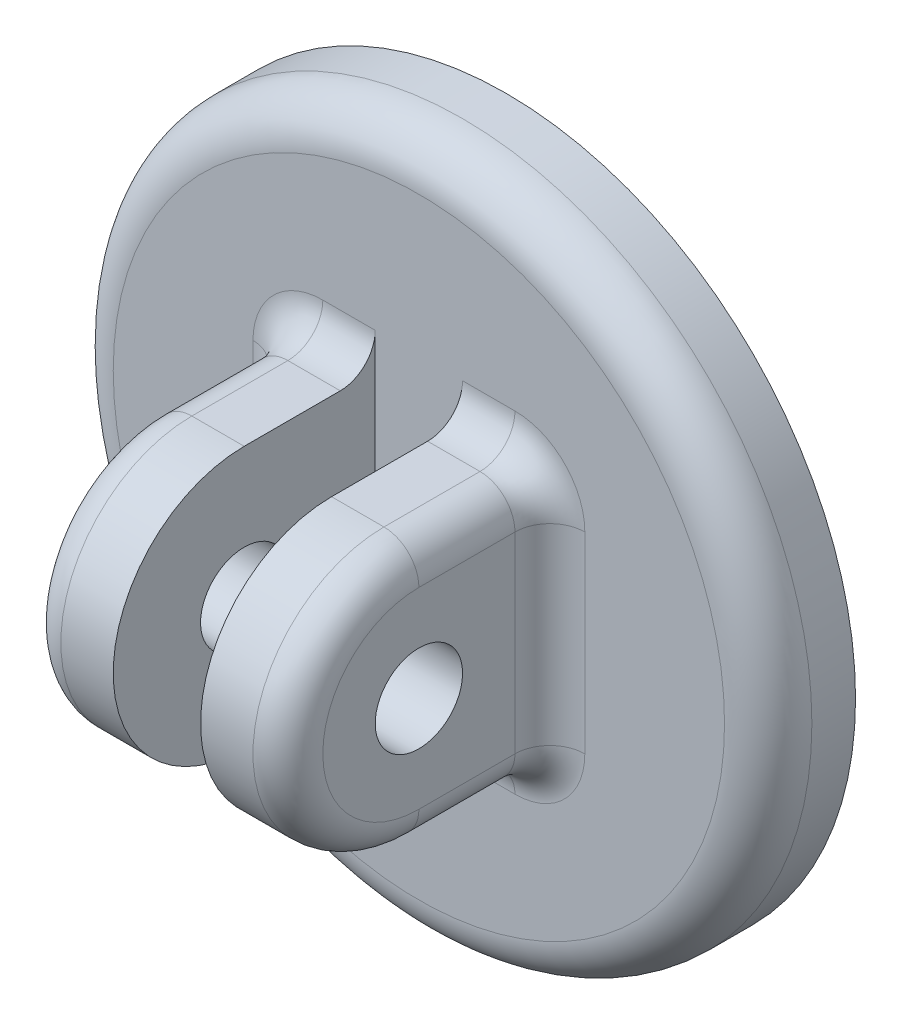
from build123d import *

# Parameters (mm, degrees)
CROQUIS1_R              = 20
SALIENTE_EXTRUIR1_DEPTH = 5
CROQUIS2_R              = 2.5
CORTAR_EXTRUIR1_DEPTH   = 5
CROQUIS3_W              = 5
CROQUIS3_H              = 15
SALIENTE_EXTRUIR3_DEPTH = 15
CROQUIS4_R              = 2.5
CORTAR_EXTRUIR2_DEPTH   = 5
FILLET1_R               = 2
FILLET2_R               = 2.5


with BuildPart() as part:
    # Croquis1 → Saliente-Extruir1 (new body)
    with BuildSketch(Plane.XY):
        Circle(CROQUIS1_R)
    extrude(amount=SALIENTE_EXTRUIR1_DEPTH)

    # Croquis2 → Cortar-Extruir1 (cut)
    with BuildSketch(Plane.XY.offset(5)):
        Circle(CROQUIS2_R)
    extrude(amount=-CORTAR_EXTRUIR1_DEPTH, mode=Mode.SUBTRACT)

    # Croquis3 → Saliente-Extruir3 (add)
    with BuildSketch(Plane.XY.offset(5)):
        with Locations((5, 0)):
            Rectangle(CROQUIS3_W, CROQUIS3_H)
    extrude(amount=SALIENTE_EXTRUIR3_DEPTH)

    # Croquis4 → Cortar-Extruir2 (cut)
    with BuildSketch(Plane(origin=(7.5, 0, 0), x_dir=(0, 0, -1), z_dir=(1, 0, 0))):
        with BuildLine():
            ThreePointArc((-12.5, -7.5), (-17.803300859, -5.303300859), (-20, 0))
            Line((-20, 0), (-20, -7.5))
            Line((-20, -7.5), (-12.5, -7.5))
        make_face()
        with BuildLine():
            ThreePointArc((-20, 0), (-17.803300859, 5.303300859), (-12.5, 7.5))
            Line((-12.5, 7.5), (-20, 7.5))
            Line((-20, 7.5), (-20, 0))
        make_face()
        with Locations((-12.5, 0)):
            Circle(CROQUIS4_R)
    extrude(amount=-CORTAR_EXTRUIR2_DEPTH, mode=Mode.SUBTRACT)

    # Simetría1: part across plane


with BuildPart() as part_1:
    add(part.part)
    add(part.part.mirror(Plane(origin=(0, 0, 0), x_dir=(0, 0, 1), z_dir=(1, 0, 0))))

    # Fillet1
    fillet1_edges = [part_1.edges().sort_by_distance(p)[0] for p in [
        (5, -7.5, 5),
        (7.5, 0, 5),
        (5, 7.5, 5),
        (7.5, -7.5, 8.75),
        (7.5, 0, 20),
        (7.5, 7.5, 8.75),
        (-5, -7.5, 5),
        (-7.5, 0, 5),
        (-5, 7.5, 5),
        (-7.5, 7.5, 8.75),
        (-7.5, -7.5, 8.75),
        (-7.5, 0, 20),
    ]]
    fillet(fillet1_edges, radius=FILLET1_R)

    # Fillet2
    fillet2_edges = [part_1.edges().sort_by_distance(p)[0] for p in [
        (-20, 0, 5),
    ]]
    fillet(fillet2_edges, radius=FILLET2_R)


solid = part_1.part
